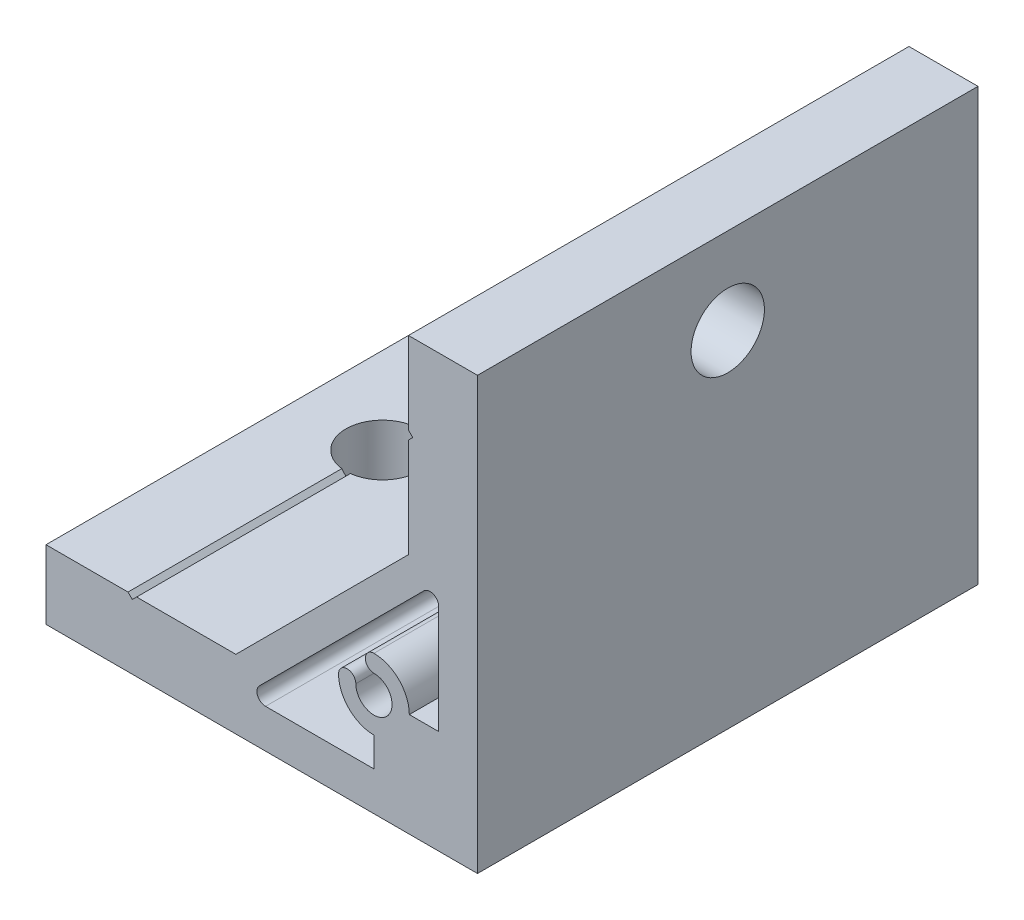
from build123d import *

# Parameters (mm, degrees)
EXTRUDE_1_DEPTH     = 29
SKETCH_2_R          = 4.25
CUT_EXTRUDE_1_DEPTH = 9
SKETCH_3_R          = 4.25
CUT_EXTRUDE_2_DEPTH = 9


with BuildPart() as part:
    # Эскиз1 → Бобышка-Вытянуть1 (new body, symmetric)
    with BuildSketch(Plane.XY):
        Polygon((-50, 0), (0, 0), (0, 50), (-8, 50), (-8, 40.5), (-7.5, 40), (-8, 39.5), (-8, 28), (-28, 8), (-39.5, 8), (-40, 7.5), (-40.5, 8), (-50, 8), align=None)
        with BuildLine():
            Line((-4.5, 12), (-4.5, 24.560303038))
            ThreePointArc((-4.5, 24.560303038), (-5.117316568, 25.484182571), (-6.207106781, 25.267409819))
            Line((-6.207106781, 25.267409819), (-25.267409819, 6.207106781))
            ThreePointArc((-25.267409819, 6.207106781), (-25.484182571, 5.117316568), (-24.560303038, 4.5))
            Line((-24.560303038, 4.5), (-12, 4.5))
            Line((-12, 4.5), (-12, 7.9))
            ThreePointArc((-12, 7.9), (-14.899137803, 9.100862197), (-16.1, 12))
            ThreePointArc((-16.1, 12), (-15.1, 13), (-14.1, 12))
            ThreePointArc((-14.1, 12), (-10.51507576, 10.51507576), (-12, 14.1))
            ThreePointArc((-12, 14.1), (-13, 15.1), (-12, 16.1))
            ThreePointArc((-12, 16.1), (-9.100862197, 14.899137803), (-7.9, 12))
            Line((-7.9, 12), (-4.5, 12))
        make_face(mode=Mode.SUBTRACT)
    extrude(amount=EXTRUDE_1_DEPTH, both=True)

    # Эскиз2 → Вырез-Вытянуть1 (cut, through all)
    with BuildSketch(Plane.ZY.offset(8)):
        with Locations(Location((0, 40, 0), (0, 0, 270))):  # turned: the seam where the file's is
            Circle(SKETCH_2_R)
    extrude(amount=-CUT_EXTRUDE_1_DEPTH, mode=Mode.SUBTRACT)

    # Эскиз3 → Вырез-Вытянуть2 (cut, through all)
    with BuildSketch(Plane(origin=(0, 8, 0), x_dir=(1, 0, 0), z_dir=(0, 1, 0))):
        with Locations(Location((-40, 0, 0), (0, 0, 180))):  # turned: the seam where the file's is
            Circle(SKETCH_3_R)
    extrude(amount=-CUT_EXTRUDE_2_DEPTH, mode=Mode.SUBTRACT)


solid = part.part
